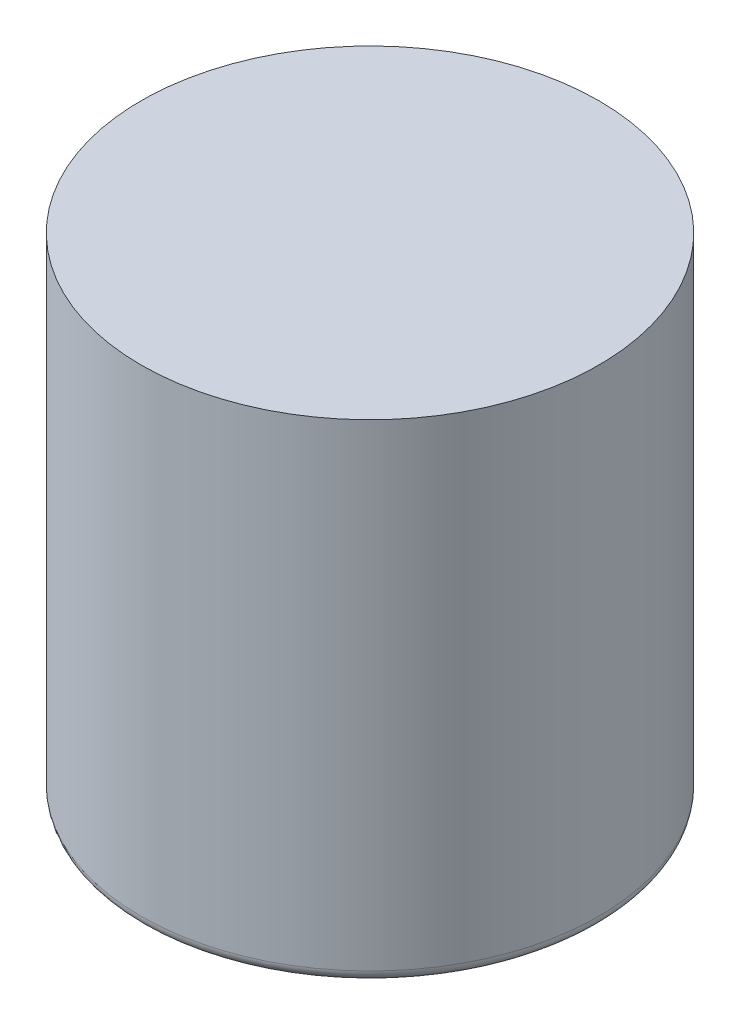
from build123d import *

# Parameters (mm, degrees)
SKETCH1_R           = 58.5
BOSS_EXTRUDE1_DEPTH = 125
FILLET1_R           = 3


with BuildPart() as part:
    # Sketch1 → Boss-Extrude1 (new body)
    with BuildSketch(Plane(origin=(0, 0, 0), x_dir=(1, 0, 0), z_dir=(0, 1, 0))):
        Circle(SKETCH1_R)
    extrude(amount=BOSS_EXTRUDE1_DEPTH)

    # Fillet1
    fillet1_edges = [part.edges().sort_by_distance(p)[0] for p in [
        (-58.5, 0, 0),
    ]]
    fillet(fillet1_edges, radius=FILLET1_R)


solid = part.part
